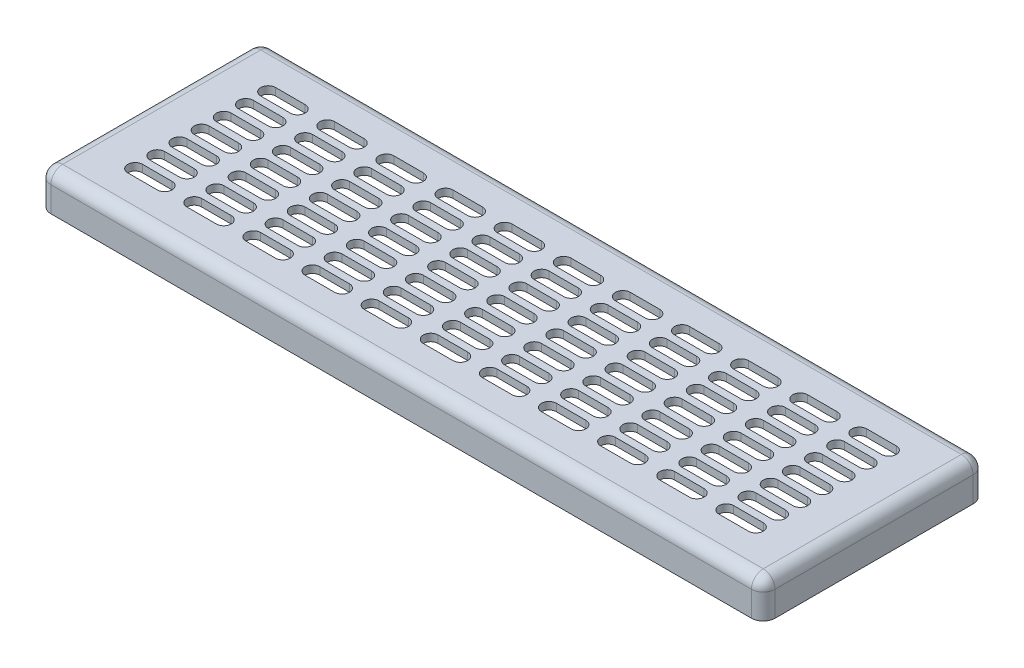
from build123d import *

# Parameters (mm, degrees)
SKETCH1_W           = 490
SKETCH1_H           = 150
BOSS_EXTRUDE1_DEPTH = 25
FILLET1_R           = 8
SHELL2_T            = -5
CUT_EXTRUDE1_DEPTH  = 26


with BuildPart() as part:
    # Sketch1 → Boss-Extrude1 (new body)
    with BuildSketch(Plane(origin=(0, 0, 0), x_dir=(1, 0, 0), z_dir=(0, 1, 0))):
        Rectangle(SKETCH1_W, SKETCH1_H)
    extrude(amount=BOSS_EXTRUDE1_DEPTH)

    # Fillet1
    fillet1_edges = [part.edges().sort_by_distance(p)[0] for p in [
        (-245, 25, 0),
        (0, 25, 75),
        (245, 25, 0),
        (0, 25, -75),
        (245, 12.5, 75),
        (-245, 12.5, 75),
        (-245, 12.5, -75),
        (245, 12.5, -75),
    ]]
    fillet(fillet1_edges, radius=FILLET1_R)

    # Shell2
    shell2_openings = [part.faces().sort_by_distance(p)[0] for p in [
        (0, 0, 0),
    ]]
    offset(amount=SHELL2_T, openings=shell2_openings, kind=Kind.INTERSECTION)

    # Sketch2 → Cut-Extrude1 (cut, through all)
    with BuildSketch(Plane(origin=(0, 25, 0), x_dir=(1, 0, 0), z_dir=(0, 1, 0))):
        with BuildLine():
            Line((-210, 50), (-190, 50))
            ThreePointArc((-190, 50), (-185, 45), (-190, 40))
            Line((-190, 40), (-210, 40))
            ThreePointArc((-210, 40), (-215, 45), (-210, 50))
        make_face()
        with BuildLine():
            Line((-170, 50), (-150, 50))
            ThreePointArc((-150, 50), (-145, 45), (-150, 40))
            Line((-150, 40), (-170, 40))
            ThreePointArc((-170, 40), (-175, 45), (-170, 50))
        make_face()
        with BuildLine():
            Line((-130, 50), (-110, 50))
            ThreePointArc((-110, 50), (-105, 45), (-110, 40))
            Line((-110, 40), (-130, 40))
            ThreePointArc((-130, 40), (-135, 45), (-130, 50))
        make_face()
        with BuildLine():
            Line((-90, 50), (-70, 50))
            ThreePointArc((-70, 50), (-65, 45), (-70, 40))
            Line((-70, 40), (-90, 40))
            ThreePointArc((-90, 40), (-95, 45), (-90, 50))
        make_face()
        with BuildLine():
            Line((-50, 50), (-30, 50))
            ThreePointArc((-30, 50), (-25, 45), (-30, 40))
            Line((-30, 40), (-50, 40))
            ThreePointArc((-50, 40), (-55, 45), (-50, 50))
        make_face()
        with BuildLine():
            Line((-10, 50), (10, 50))
            ThreePointArc((10, 50), (15, 45), (10, 40))
            Line((10, 40), (-10, 40))
            ThreePointArc((-10, 40), (-15, 45), (-10, 50))
        make_face()
        with BuildLine():
            Line((30, 50), (50, 50))
            ThreePointArc((50, 50), (55, 45), (50, 40))
            Line((50, 40), (30, 40))
            ThreePointArc((30, 40), (25, 45), (30, 50))
        make_face()
        with BuildLine():
            Line((70, 50), (90, 50))
            ThreePointArc((90, 50), (95, 45), (90, 40))
            Line((90, 40), (70, 40))
            ThreePointArc((70, 40), (65, 45), (70, 50))
        make_face()
        with BuildLine():
            Line((110, 50), (130, 50))
            ThreePointArc((130, 50), (135, 45), (130, 40))
            Line((130, 40), (110, 40))
            ThreePointArc((110, 40), (105, 45), (110, 50))
        make_face()
        with BuildLine():
            Line((150, 50), (170, 50))
            ThreePointArc((170, 50), (175, 45), (170, 40))
            Line((170, 40), (150, 40))
            ThreePointArc((150, 40), (145, 45), (150, 50))
        make_face()
        with BuildLine():
            Line((190, 50), (210, 50))
            ThreePointArc((210, 50), (215, 45), (210, 40))
            Line((210, 40), (190, 40))
            ThreePointArc((190, 40), (185, 45), (190, 50))
        make_face()
        with BuildLine():
            Line((-170, 35), (-150, 35))
            ThreePointArc((-150, 35), (-145, 30), (-150, 25))
            Line((-150, 25), (-170, 25))
            ThreePointArc((-170, 25), (-175, 30), (-170, 35))
        make_face()
        with BuildLine():
            Line((-130, 35), (-110, 35))
            ThreePointArc((-110, 35), (-105, 30), (-110, 25))
            Line((-110, 25), (-130, 25))
            ThreePointArc((-130, 25), (-135, 30), (-130, 35))
        make_face()
        with BuildLine():
            Line((-90, 35), (-70, 35))
            ThreePointArc((-70, 35), (-65, 30), (-70, 25))
            Line((-70, 25), (-90, 25))
            ThreePointArc((-90, 25), (-95, 30), (-90, 35))
        make_face()
        with BuildLine():
            Line((-50, 35), (-30, 35))
            ThreePointArc((-30, 35), (-25, 30), (-30, 25))
            Line((-30, 25), (-50, 25))
            ThreePointArc((-50, 25), (-55, 30), (-50, 35))
        make_face()
        with BuildLine():
            Line((-10, 35), (10, 35))
            ThreePointArc((10, 35), (15, 30), (10, 25))
            Line((10, 25), (-10, 25))
            ThreePointArc((-10, 25), (-15, 30), (-10, 35))
        make_face()
        with BuildLine():
            Line((30, 35), (50, 35))
            ThreePointArc((50, 35), (55, 30), (50, 25))
            Line((50, 25), (30, 25))
            ThreePointArc((30, 25), (25, 30), (30, 35))
        make_face()
        with BuildLine():
            Line((70, 35), (90, 35))
            ThreePointArc((90, 35), (95, 30), (90, 25))
            Line((90, 25), (70, 25))
            ThreePointArc((70, 25), (65, 30), (70, 35))
        make_face()
        with BuildLine():
            Line((110, 35), (130, 35))
            ThreePointArc((130, 35), (135, 30), (130, 25))
            Line((130, 25), (110, 25))
            ThreePointArc((110, 25), (105, 30), (110, 35))
        make_face()
        with BuildLine():
            Line((150, 35), (170, 35))
            ThreePointArc((170, 35), (175, 30), (170, 25))
            Line((170, 25), (150, 25))
            ThreePointArc((150, 25), (145, 30), (150, 35))
        make_face()
        with BuildLine():
            Line((190, 35), (210, 35))
            ThreePointArc((210, 35), (215, 30), (210, 25))
            Line((210, 25), (190, 25))
            ThreePointArc((190, 25), (185, 30), (190, 35))
        make_face()
        with BuildLine():
            Line((-170, 20), (-150, 20))
            ThreePointArc((-150, 20), (-145, 15), (-150, 10))
            Line((-150, 10), (-170, 10))
            ThreePointArc((-170, 10), (-175, 15), (-170, 20))
        make_face()
        with BuildLine():
            Line((-130, 20), (-110, 20))
            ThreePointArc((-110, 20), (-105, 15), (-110, 10))
            Line((-110, 10), (-130, 10))
            ThreePointArc((-130, 10), (-135, 15), (-130, 20))
        make_face()
        with BuildLine():
            Line((-90, 20), (-70, 20))
            ThreePointArc((-70, 20), (-65, 15), (-70, 10))
            Line((-70, 10), (-90, 10))
            ThreePointArc((-90, 10), (-95, 15), (-90, 20))
        make_face()
        with BuildLine():
            Line((-50, 20), (-30, 20))
            ThreePointArc((-30, 20), (-25, 15), (-30, 10))
            Line((-30, 10), (-50, 10))
            ThreePointArc((-50, 10), (-55, 15), (-50, 20))
        make_face()
        with BuildLine():
            Line((-10, 20), (10, 20))
            ThreePointArc((10, 20), (15, 15), (10, 10))
            Line((10, 10), (-10, 10))
            ThreePointArc((-10, 10), (-15, 15), (-10, 20))
        make_face()
        with BuildLine():
            Line((30, 20), (50, 20))
            ThreePointArc((50, 20), (55, 15), (50, 10))
            Line((50, 10), (30, 10))
            ThreePointArc((30, 10), (25, 15), (30, 20))
        make_face()
        with BuildLine():
            Line((70, 20), (90, 20))
            ThreePointArc((90, 20), (95, 15), (90, 10))
            Line((90, 10), (70, 10))
            ThreePointArc((70, 10), (65, 15), (70, 20))
        make_face()
        with BuildLine():
            Line((110, 20), (130, 20))
            ThreePointArc((130, 20), (135, 15), (130, 10))
            Line((130, 10), (110, 10))
            ThreePointArc((110, 10), (105, 15), (110, 20))
        make_face()
        with BuildLine():
            Line((150, 20), (170, 20))
            ThreePointArc((170, 20), (175, 15), (170, 10))
            Line((170, 10), (150, 10))
            ThreePointArc((150, 10), (145, 15), (150, 20))
        make_face()
        with BuildLine():
            Line((190, 20), (210, 20))
            ThreePointArc((210, 20), (215, 15), (210, 10))
            Line((210, 10), (190, 10))
            ThreePointArc((190, 10), (185, 15), (190, 20))
        make_face()
        with BuildLine():
            Line((-170, 5), (-150, 5))
            ThreePointArc((-150, 5), (-145, 0), (-150, -5))
            Line((-150, -5), (-170, -5))
            ThreePointArc((-170, -5), (-175, 0), (-170, 5))
        make_face()
        with BuildLine():
            Line((-130, 5), (-110, 5))
            ThreePointArc((-110, 5), (-105, 0), (-110, -5))
            Line((-110, -5), (-130, -5))
            ThreePointArc((-130, -5), (-135, 0), (-130, 5))
        make_face()
        with BuildLine():
            Line((-90, 5), (-70, 5))
            ThreePointArc((-70, 5), (-65, 0), (-70, -5))
            Line((-70, -5), (-90, -5))
            ThreePointArc((-90, -5), (-95, 0), (-90, 5))
        make_face()
        with BuildLine():
            Line((-50, 5), (-30, 5))
            ThreePointArc((-30, 5), (-25, 0), (-30, -5))
            Line((-30, -5), (-50, -5))
            ThreePointArc((-50, -5), (-55, 0), (-50, 5))
        make_face()
        with BuildLine():
            Line((-10, 5), (10, 5))
            ThreePointArc((10, 5), (15, 0), (10, -5))
            Line((10, -5), (-10, -5))
            ThreePointArc((-10, -5), (-15, 0), (-10, 5))
        make_face()
        with BuildLine():
            Line((30, 5), (50, 5))
            ThreePointArc((50, 5), (55, 0), (50, -5))
            Line((50, -5), (30, -5))
            ThreePointArc((30, -5), (25, 0), (30, 5))
        make_face()
        with BuildLine():
            Line((70, 5), (90, 5))
            ThreePointArc((90, 5), (95, 0), (90, -5))
            Line((90, -5), (70, -5))
            ThreePointArc((70, -5), (65, 0), (70, 5))
        make_face()
        with BuildLine():
            Line((110, 5), (130, 5))
            ThreePointArc((130, 5), (135, 0), (130, -5))
            Line((130, -5), (110, -5))
            ThreePointArc((110, -5), (105, 0), (110, 5))
        make_face()
        with BuildLine():
            Line((150, 5), (170, 5))
            ThreePointArc((170, 5), (175, 0), (170, -5))
            Line((170, -5), (150, -5))
            ThreePointArc((150, -5), (145, 0), (150, 5))
        make_face()
        with BuildLine():
            Line((190, 5), (210, 5))
            ThreePointArc((210, 5), (215, 0), (210, -5))
            Line((210, -5), (190, -5))
            ThreePointArc((190, -5), (185, 0), (190, 5))
        make_face()
        with BuildLine():
            Line((-170, -10), (-150, -10))
            ThreePointArc((-150, -10), (-145, -15), (-150, -20))
            Line((-150, -20), (-170, -20))
            ThreePointArc((-170, -20), (-175, -15), (-170, -10))
        make_face()
        with BuildLine():
            Line((-130, -10), (-110, -10))
            ThreePointArc((-110, -10), (-105, -15), (-110, -20))
            Line((-110, -20), (-130, -20))
            ThreePointArc((-130, -20), (-135, -15), (-130, -10))
        make_face()
        with BuildLine():
            Line((-90, -10), (-70, -10))
            ThreePointArc((-70, -10), (-65, -15), (-70, -20))
            Line((-70, -20), (-90, -20))
            ThreePointArc((-90, -20), (-95, -15), (-90, -10))
        make_face()
        with BuildLine():
            Line((-50, -10), (-30, -10))
            ThreePointArc((-30, -10), (-25, -15), (-30, -20))
            Line((-30, -20), (-50, -20))
            ThreePointArc((-50, -20), (-55, -15), (-50, -10))
        make_face()
        with BuildLine():
            Line((-10, -10), (10, -10))
            ThreePointArc((10, -10), (15, -15), (10, -20))
            Line((10, -20), (-10, -20))
            ThreePointArc((-10, -20), (-15, -15), (-10, -10))
        make_face()
        with BuildLine():
            Line((30, -10), (50, -10))
            ThreePointArc((50, -10), (55, -15), (50, -20))
            Line((50, -20), (30, -20))
            ThreePointArc((30, -20), (25, -15), (30, -10))
        make_face()
        with BuildLine():
            Line((70, -10), (90, -10))
            ThreePointArc((90, -10), (95, -15), (90, -20))
            Line((90, -20), (70, -20))
            ThreePointArc((70, -20), (65, -15), (70, -10))
        make_face()
        with BuildLine():
            Line((110, -10), (130, -10))
            ThreePointArc((130, -10), (135, -15), (130, -20))
            Line((130, -20), (110, -20))
            ThreePointArc((110, -20), (105, -15), (110, -10))
        make_face()
        with BuildLine():
            Line((150, -10), (170, -10))
            ThreePointArc((170, -10), (175, -15), (170, -20))
            Line((170, -20), (150, -20))
            ThreePointArc((150, -20), (145, -15), (150, -10))
        make_face()
        with BuildLine():
            Line((190, -10), (210, -10))
            ThreePointArc((210, -10), (215, -15), (210, -20))
            Line((210, -20), (190, -20))
            ThreePointArc((190, -20), (185, -15), (190, -10))
        make_face()
        with BuildLine():
            Line((-170, -25), (-150, -25))
            ThreePointArc((-150, -25), (-145, -30), (-150, -35))
            Line((-150, -35), (-170, -35))
            ThreePointArc((-170, -35), (-175, -30), (-170, -25))
        make_face()
        with BuildLine():
            Line((-130, -25), (-110, -25))
            ThreePointArc((-110, -25), (-105, -30), (-110, -35))
            Line((-110, -35), (-130, -35))
            ThreePointArc((-130, -35), (-135, -30), (-130, -25))
        make_face()
        with BuildLine():
            Line((-90, -25), (-70, -25))
            ThreePointArc((-70, -25), (-65, -30), (-70, -35))
            Line((-70, -35), (-90, -35))
            ThreePointArc((-90, -35), (-95, -30), (-90, -25))
        make_face()
        with BuildLine():
            Line((-50, -25), (-30, -25))
            ThreePointArc((-30, -25), (-25, -30), (-30, -35))
            Line((-30, -35), (-50, -35))
            ThreePointArc((-50, -35), (-55, -30), (-50, -25))
        make_face()
        with BuildLine():
            Line((-10, -25), (10, -25))
            ThreePointArc((10, -25), (15, -30), (10, -35))
            Line((10, -35), (-10, -35))
            ThreePointArc((-10, -35), (-15, -30), (-10, -25))
        make_face()
        with BuildLine():
            Line((30, -25), (50, -25))
            ThreePointArc((50, -25), (55, -30), (50, -35))
            Line((50, -35), (30, -35))
            ThreePointArc((30, -35), (25, -30), (30, -25))
        make_face()
        with BuildLine():
            Line((70, -25), (90, -25))
            ThreePointArc((90, -25), (95, -30), (90, -35))
            Line((90, -35), (70, -35))
            ThreePointArc((70, -35), (65, -30), (70, -25))
        make_face()
        with BuildLine():
            Line((110, -25), (130, -25))
            ThreePointArc((130, -25), (135, -30), (130, -35))
            Line((130, -35), (110, -35))
            ThreePointArc((110, -35), (105, -30), (110, -25))
        make_face()
        with BuildLine():
            Line((150, -25), (170, -25))
            ThreePointArc((170, -25), (175, -30), (170, -35))
            Line((170, -35), (150, -35))
            ThreePointArc((150, -35), (145, -30), (150, -25))
        make_face()
        with BuildLine():
            Line((190, -25), (210, -25))
            ThreePointArc((210, -25), (215, -30), (210, -35))
            Line((210, -35), (190, -35))
            ThreePointArc((190, -35), (185, -30), (190, -25))
        make_face()
        with BuildLine():
            Line((-170, -40), (-150, -40))
            ThreePointArc((-150, -40), (-145, -45), (-150, -50))
            Line((-150, -50), (-170, -50))
            ThreePointArc((-170, -50), (-175, -45), (-170, -40))
        make_face()
        with BuildLine():
            Line((-130, -40), (-110, -40))
            ThreePointArc((-110, -40), (-105, -45), (-110, -50))
            Line((-110, -50), (-130, -50))
            ThreePointArc((-130, -50), (-135, -45), (-130, -40))
        make_face()
        with BuildLine():
            Line((-90, -40), (-70, -40))
            ThreePointArc((-70, -40), (-65, -45), (-70, -50))
            Line((-70, -50), (-90, -50))
            ThreePointArc((-90, -50), (-95, -45), (-90, -40))
        make_face()
        with BuildLine():
            Line((-50, -40), (-30, -40))
            ThreePointArc((-30, -40), (-25, -45), (-30, -50))
            Line((-30, -50), (-50, -50))
            ThreePointArc((-50, -50), (-55, -45), (-50, -40))
        make_face()
        with BuildLine():
            Line((-10, -40), (10, -40))
            ThreePointArc((10, -40), (15, -45), (10, -50))
            Line((10, -50), (-10, -50))
            ThreePointArc((-10, -50), (-15, -45), (-10, -40))
        make_face()
        with BuildLine():
            Line((30, -40), (50, -40))
            ThreePointArc((50, -40), (55, -45), (50, -50))
            Line((50, -50), (30, -50))
            ThreePointArc((30, -50), (25, -45), (30, -40))
        make_face()
        with BuildLine():
            Line((70, -40), (90, -40))
            ThreePointArc((90, -40), (95, -45), (90, -50))
            Line((90, -50), (70, -50))
            ThreePointArc((70, -50), (65, -45), (70, -40))
        make_face()
        with BuildLine():
            Line((110, -40), (130, -40))
            ThreePointArc((130, -40), (135, -45), (130, -50))
            Line((130, -50), (110, -50))
            ThreePointArc((110, -50), (105, -45), (110, -40))
        make_face()
        with BuildLine():
            Line((150, -40), (170, -40))
            ThreePointArc((170, -40), (175, -45), (170, -50))
            Line((170, -50), (150, -50))
            ThreePointArc((150, -50), (145, -45), (150, -40))
        make_face()
        with BuildLine():
            Line((190, -40), (210, -40))
            ThreePointArc((210, -40), (215, -45), (210, -50))
            Line((210, -50), (190, -50))
            ThreePointArc((190, -50), (185, -45), (190, -40))
        make_face()
        with BuildLine():
            Line((-210, 35), (-190, 35))
            ThreePointArc((-190, 35), (-185, 30), (-190, 25))
            Line((-190, 25), (-210, 25))
            ThreePointArc((-210, 25), (-215, 30), (-210, 35))
        make_face()
        with BuildLine():
            Line((-210, 20), (-190, 20))
            ThreePointArc((-190, 20), (-185, 15), (-190, 10))
            Line((-190, 10), (-210, 10))
            ThreePointArc((-210, 10), (-215, 15), (-210, 20))
        make_face()
        with BuildLine():
            Line((-210, 5), (-190, 5))
            ThreePointArc((-190, 5), (-185, 0), (-190, -5))
            Line((-190, -5), (-210, -5))
            ThreePointArc((-210, -5), (-215, 0), (-210, 5))
        make_face()
        with BuildLine():
            Line((-210, -10), (-190, -10))
            ThreePointArc((-190, -10), (-185, -15), (-190, -20))
            Line((-190, -20), (-210, -20))
            ThreePointArc((-210, -20), (-215, -15), (-210, -10))
        make_face()
        with BuildLine():
            Line((-210, -25), (-190, -25))
            ThreePointArc((-190, -25), (-185, -30), (-190, -35))
            Line((-190, -35), (-210, -35))
            ThreePointArc((-210, -35), (-215, -30), (-210, -25))
        make_face()
        with BuildLine():
            Line((-210, -40), (-190, -40))
            ThreePointArc((-190, -40), (-185, -45), (-190, -50))
            Line((-190, -50), (-210, -50))
            ThreePointArc((-210, -50), (-215, -45), (-210, -40))
        make_face()
    extrude(amount=-CUT_EXTRUDE1_DEPTH, mode=Mode.SUBTRACT)


solid = part.part
